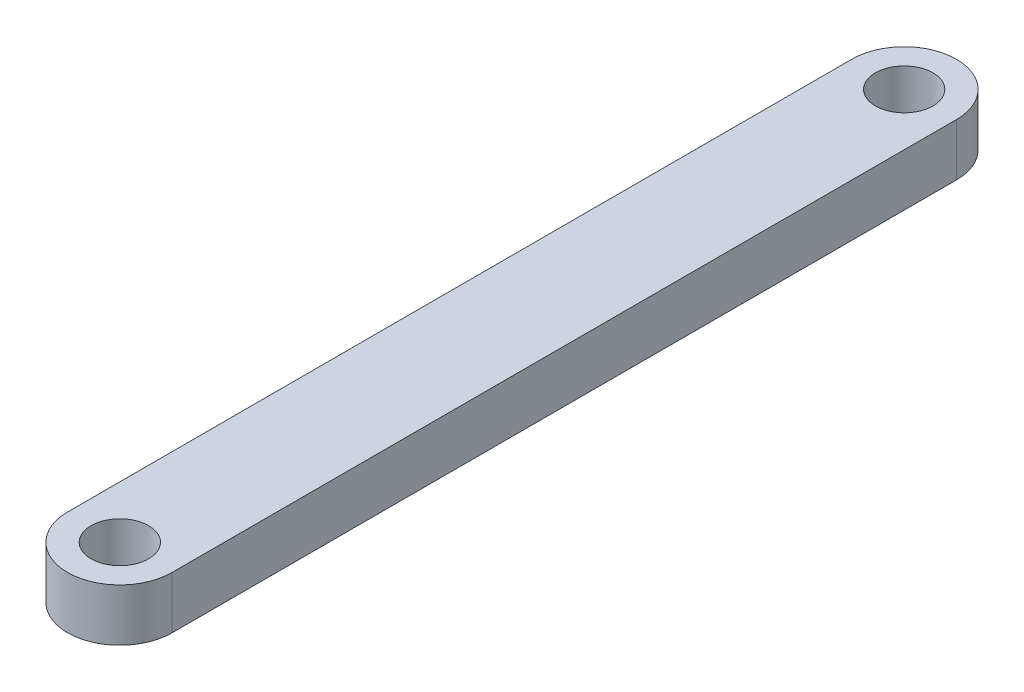
from build123d import *

# Parameters (mm, degrees)
SKETCH1_R           = 2.75
BOSS_EXTRUDE1_DEPTH = 5


with BuildPart() as part:
    # Sketch1 → Boss-Extrude1 (new body)
    with BuildSketch(Plane(origin=(0, 0, 0), x_dir=(1, 0, 0), z_dir=(0, 1, 0))):
        with BuildLine():
            Line((5, 75), (5, 0))
            ThreePointArc((5, 0), (0, -5), (-5, 0))
            Line((-5, 0), (-5, 75))
            ThreePointArc((-5, 75), (0, 80), (5, 75))
        make_face()
        with Locations((0, 75)):
            Circle(SKETCH1_R, mode=Mode.SUBTRACT)
        Circle(SKETCH1_R, mode=Mode.SUBTRACT)
    extrude(amount=BOSS_EXTRUDE1_DEPTH)


solid = part.part
